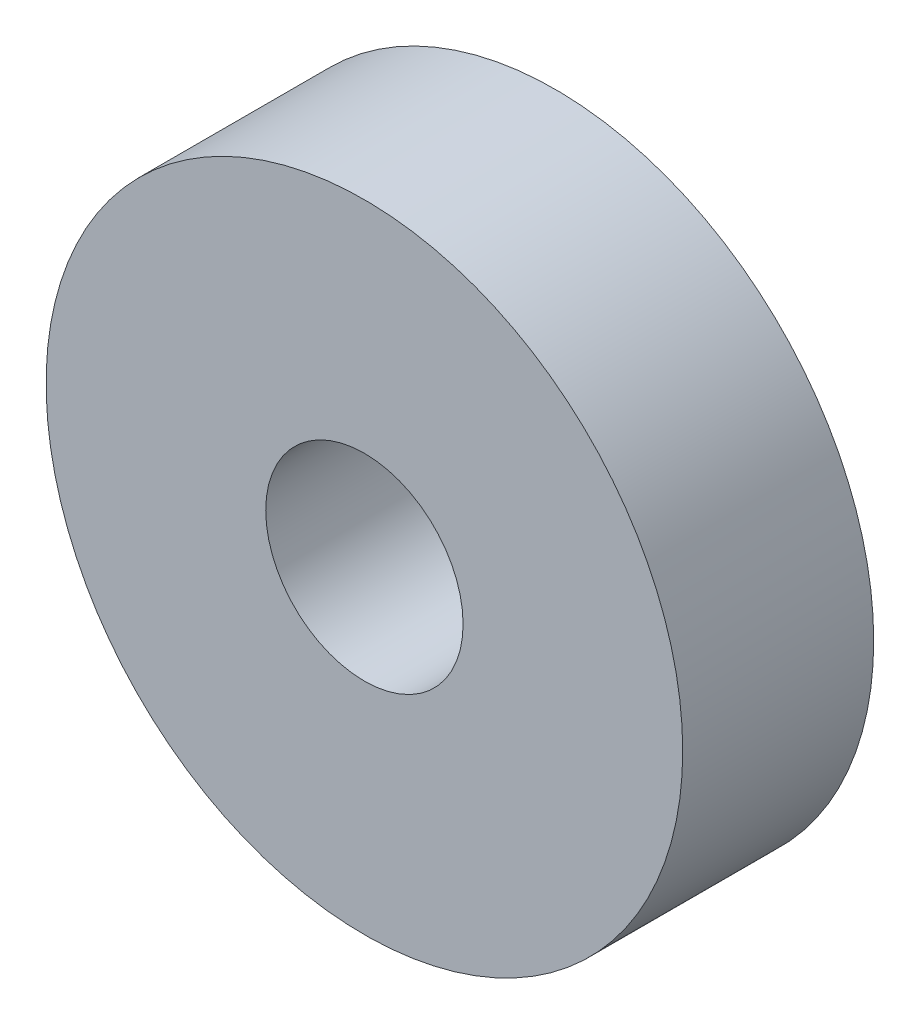
from build123d import *

# Parameters (mm, degrees)
MODEL_R             = 5.000000001
MODEL_R_2           = 1.55
BOSS_EXTRUDE1_DEPTH = 3


with BuildPart() as part:
    # Model → Boss-Extrude1 (new body)
    with BuildSketch(Plane.XY):
        with Locations((41.999999999, 46)):
            Circle(MODEL_R)
        with Locations((41.999999999, 46)):
            Circle(MODEL_R_2, mode=Mode.SUBTRACT)
    extrude(amount=BOSS_EXTRUDE1_DEPTH)


solid = part.part
